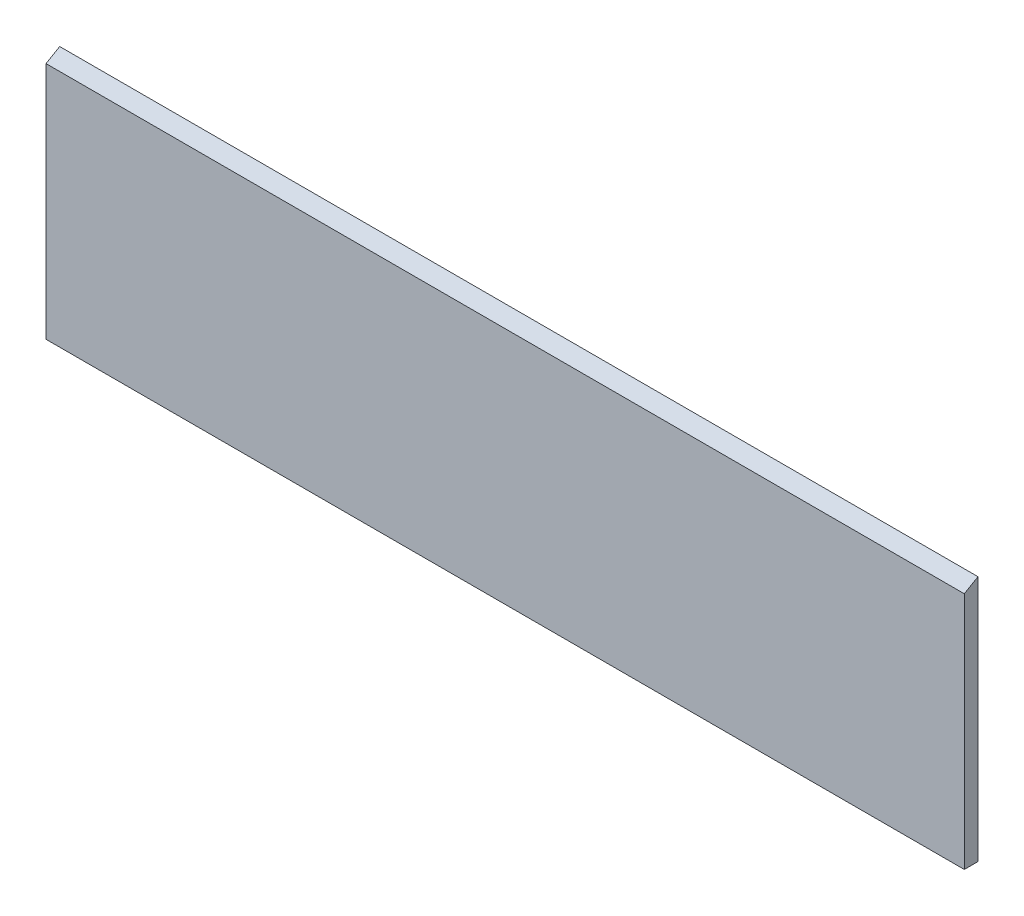
from build123d import *

# Parameters (mm, degrees)
SKETCH1_W      = 670
SKETCH1_H      = 180
EXTRUDE1_DEPTH = 10
EXTRUDE2_DEPTH = 671


with BuildPart() as part:
    # Sketch1 → Extrude1 (new body)
    with BuildSketch(Plane.XY):
        with Locations((335, 90)):
            Rectangle(SKETCH1_W, SKETCH1_H)
    extrude(amount=EXTRUDE1_DEPTH)

    # Sketch2 → Extrude2 (cut, through all)
    with BuildSketch(Plane(origin=(670, 0, 0), x_dir=(0, 0, -1), z_dir=(1, 0, 0))):
        Polygon((0, 180), (-10, 174.226497308), (-10, 180), align=None)
    extrude(amount=-EXTRUDE2_DEPTH, mode=Mode.SUBTRACT)


solid = part.part
